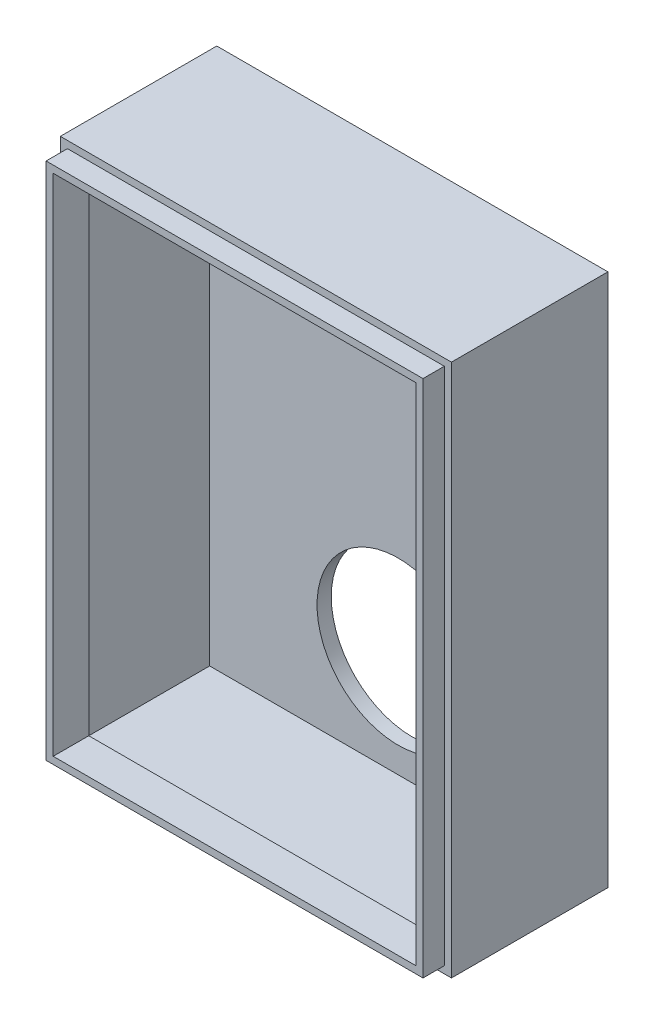
from build123d import *

# Parameters (mm, degrees)
SKETCH_1_W           = 55
SKETCH_1_H           = 75
EXTRUDE_1_DEPTH      = 2
SKETCH_2_W           = 55
SKETCH_2_H           = 75
SKETCH_2_W_2         = 53
SKETCH_2_H_2         = 73
EXTRUDE_2_DEPTH      = 20
SKETCH_3_W           = 53
SKETCH_3_H           = 73
SKETCH_3_W_2         = 51
SKETCH_3_H_2         = 71
EXTRUDE_3_DEPTH      = 3
EXTRUDE_3_DEPTH_BACK = 2
SKETCH_4_R           = 11.4
SKETCH_4_R_2         = 4
CUT_EXTRUDE_1_DEPTH  = 3


with BuildPart() as part:
    # Эскиз1 → Бобышка-Вытянуть1 (new body)
    with BuildSketch(Plane.XY):
        with Locations((27.5, 37.5)):
            Rectangle(SKETCH_1_W, SKETCH_1_H)
    extrude(amount=EXTRUDE_1_DEPTH)

    # Эскиз2 → Бобышка-Вытянуть2 (add)
    with BuildSketch(Plane.XY.offset(2)):
        with Locations((27.5, 37.5)):
            Rectangle(SKETCH_2_W, SKETCH_2_H)
        with Locations((27.5, 37.5)):
            Rectangle(SKETCH_2_W_2, SKETCH_2_H_2, mode=Mode.SUBTRACT)
    extrude(amount=EXTRUDE_2_DEPTH)

    # Эскиз4 → Вырез-Вытянуть1 (cut)
    with BuildSketch(Plane.XY.offset(2)):
        with Locations((27.5, 16)):
            Circle(SKETCH_4_R)
        with Locations((27.5, 63)):
            Circle(SKETCH_4_R_2)
    extrude(amount=-CUT_EXTRUDE_1_DEPTH, mode=Mode.SUBTRACT)


with BuildPart() as body_2:
    # Эскиз3 → Бобышка-Вытянуть3 (new body, two sides)
    with BuildSketch(Plane.XY.offset(22)) as extrude_3_sk:
        with Locations((27.5, 37.5)):
            Rectangle(SKETCH_3_W, SKETCH_3_H)
        with Locations((27.5, 37.5)):
            Rectangle(SKETCH_3_W_2, SKETCH_3_H_2, mode=Mode.SUBTRACT)
    extrude(amount=EXTRUDE_3_DEPTH)
    extrude(extrude_3_sk.sketch, amount=-EXTRUDE_3_DEPTH_BACK)


solid = Compound([part.part, body_2.part])
